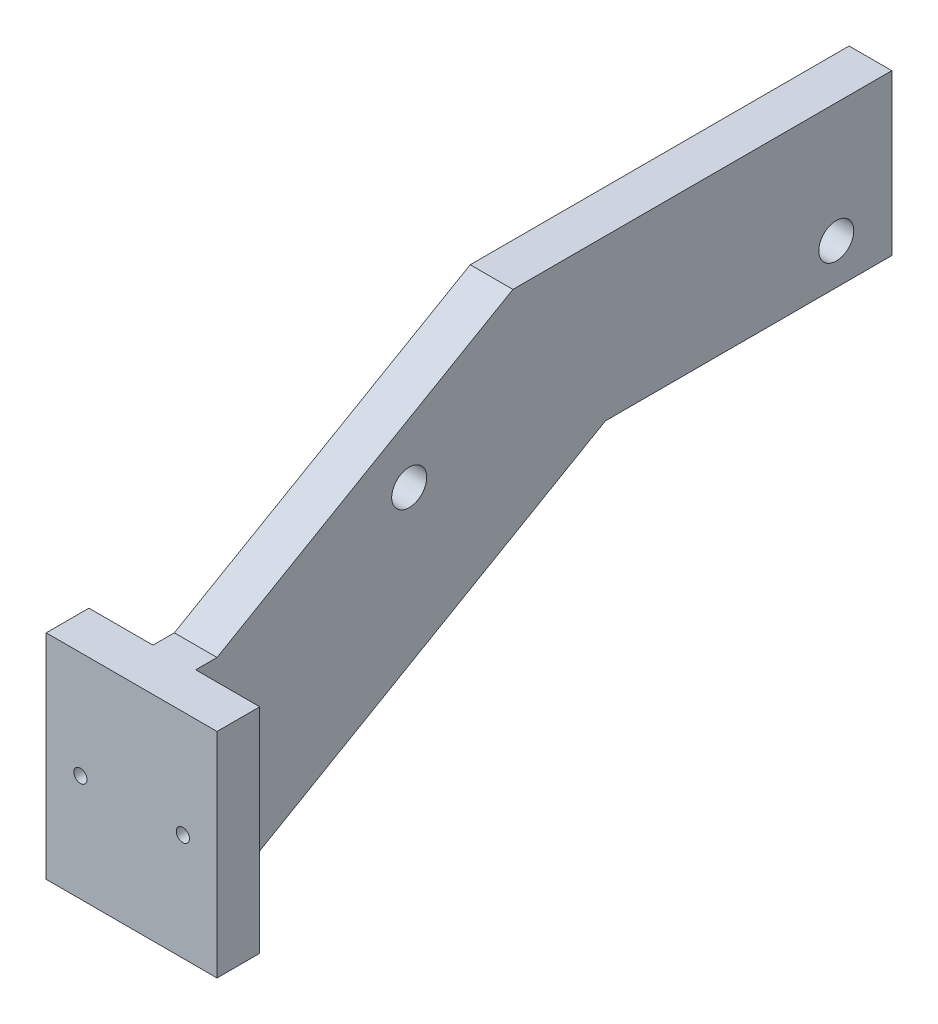
from build123d import *

# Parameters (mm, degrees)
SALIENTE_EXTRUIR1_DEPTH = 10
SALIENTE_EXTRUIR2_DEPTH = 10
CROQUIS3_R              = 1.55
CORTAR_EXTRUIR1_DEPTH   = 10
CROQUIS4_R              = 4.1
CORTAR_EXTRUIR2_DEPTH   = 10


with BuildPart() as part:
    # Croquis1 → Saliente-Extruir1 (new body)
    with BuildSketch(Plane(origin=(0, 0, 0), x_dir=(0, 0, -1), z_dir=(1, 0, 0))):
        Polygon((0, 0), (0, 50), (15, 50), (84.282032303, 90), (173.002060716, 90), (173.002060716, 52.5), (105.932667397, 52.5), (15, 0), align=None)
    extrude(amount=SALIENTE_EXTRUIR1_DEPTH)

    # Croquis2 → Saliente-Extruir2 (add)
    with BuildSketch(Plane.XY):
        Polygon((0, 50), (-15, 50), (-15, 0), (25, 0), (25, 50), align=None)
    extrude(amount=-SALIENTE_EXTRUIR2_DEPTH)

    # Croquis3 → Cortar-Extruir1 (cut)
    with BuildSketch(Plane.XY):
        with Locations((-7, 25)):
            Circle(CROQUIS3_R)
        with Locations((17, 25)):
            Circle(CROQUIS3_R)
    extrude(amount=-CORTAR_EXTRUIR1_DEPTH, mode=Mode.SUBTRACT)

    # Croquis4 → Cortar-Extruir2 (cut)
    with BuildSketch(Plane(origin=(10, 0, 0), x_dir=(0, 0, -1), z_dir=(1, 0, 0))):
        with Locations((60, 62)):
            Circle(CROQUIS4_R)
        with Locations((160, 62)):
            Circle(CROQUIS4_R)
    extrude(amount=-CORTAR_EXTRUIR2_DEPTH, mode=Mode.SUBTRACT)


solid = part.part
